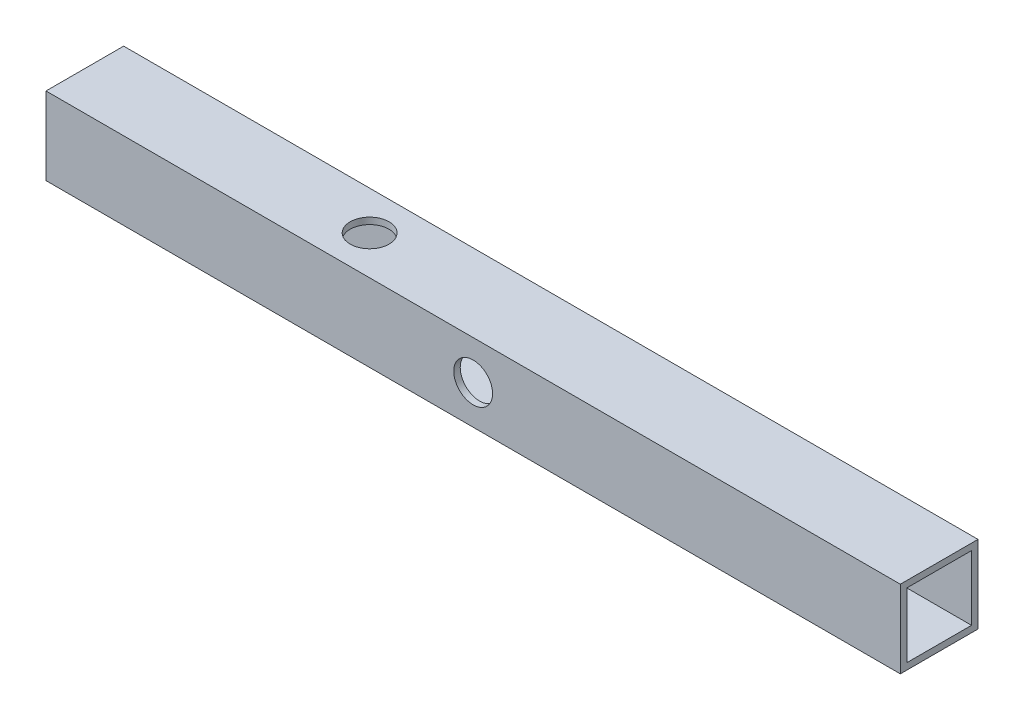
from build123d import *

# Parameters (mm, degrees)
SKETCH1_W                     = 19.05
SKETCH1_H                     = 19.05
SKETCH1_W_2                   = 15.875
SKETCH1_H_2                   = 15.875
BOSS_EXTRUDE1_DEPTH           = 104.775
POWERSUPPLY_MOUNT_HOLES_REACH = 21.05
SKETCH4_R                     = 4.7625
CUT_EXTRUDE1_REACH            = 21.05
SKETCH5_R                     = 4.7625
SKETCH6_R                     = 4.7625
CUT_EXTRUDE2_DEPTH            = 20.05


with BuildPart() as part:
    # Sketch1 → Boss-Extrude1 (new body, symmetric)
    with BuildSketch(Plane(origin=(0, 0, 0), x_dir=(0, -1, 0), z_dir=(1, 0, 0))):
        Rectangle(SKETCH1_W, SKETCH1_H)
        Rectangle(SKETCH1_W_2, SKETCH1_H_2, mode=Mode.SUBTRACT)
    extrude(amount=BOSS_EXTRUDE1_DEPTH, both=True)

    # Sketch4 → PowerSupply Mount Holes (cut, up to next)
    with BuildSketch(Plane.XY.offset(-9.525), mode=Mode.PRIVATE) as powersupply_mount_holes_sk1:
        with Locations((-69.85, 0)):
            Circle(SKETCH4_R)
    powersupply_mount_holes_tool1 = extrude(powersupply_mount_holes_sk1.sketch, amount=POWERSUPPLY_MOUNT_HOLES_REACH, mode=Mode.PRIVATE) & part.part
    add(powersupply_mount_holes_tool1.solids().sort_by_distance((-69.85, 0, -9.525))[0], mode=Mode.SUBTRACT)
    # Sketch4 → PowerSupply Mount Holes (cut, up to next)
    with BuildSketch(Plane.XY.offset(-9.525), mode=Mode.PRIVATE) as powersupply_mount_holes_sk2:
        with Locations((69.85, 0)):
            Circle(SKETCH4_R)
    powersupply_mount_holes_tool2 = extrude(powersupply_mount_holes_sk2.sketch, amount=POWERSUPPLY_MOUNT_HOLES_REACH, mode=Mode.PRIVATE) & part.part
    add(powersupply_mount_holes_tool2.solids().sort_by_distance((69.85, 0, -9.525))[0], mode=Mode.SUBTRACT)

    # Sketch5 → Cut-Extrude1 (cut, up to next)
    with BuildSketch(Plane.XY.offset(9.525), mode=Mode.PRIVATE) as cut_extrude1_sk1:
        Circle(SKETCH5_R)
    cut_extrude1_tool1 = extrude(cut_extrude1_sk1.sketch, amount=-CUT_EXTRUDE1_REACH, mode=Mode.PRIVATE) & part.part
    add(cut_extrude1_tool1.solids().sort_by_distance((0, 0, 9.525))[0], mode=Mode.SUBTRACT)

    # Sketch6 → Cut-Extrude2 (cut, through all)
    with BuildSketch(Plane.XZ.offset(-9.525)):
        with Locations((-34.925, 0)):
            Circle(SKETCH6_R)
    extrude(amount=CUT_EXTRUDE2_DEPTH, mode=Mode.SUBTRACT)


solid = part.part
